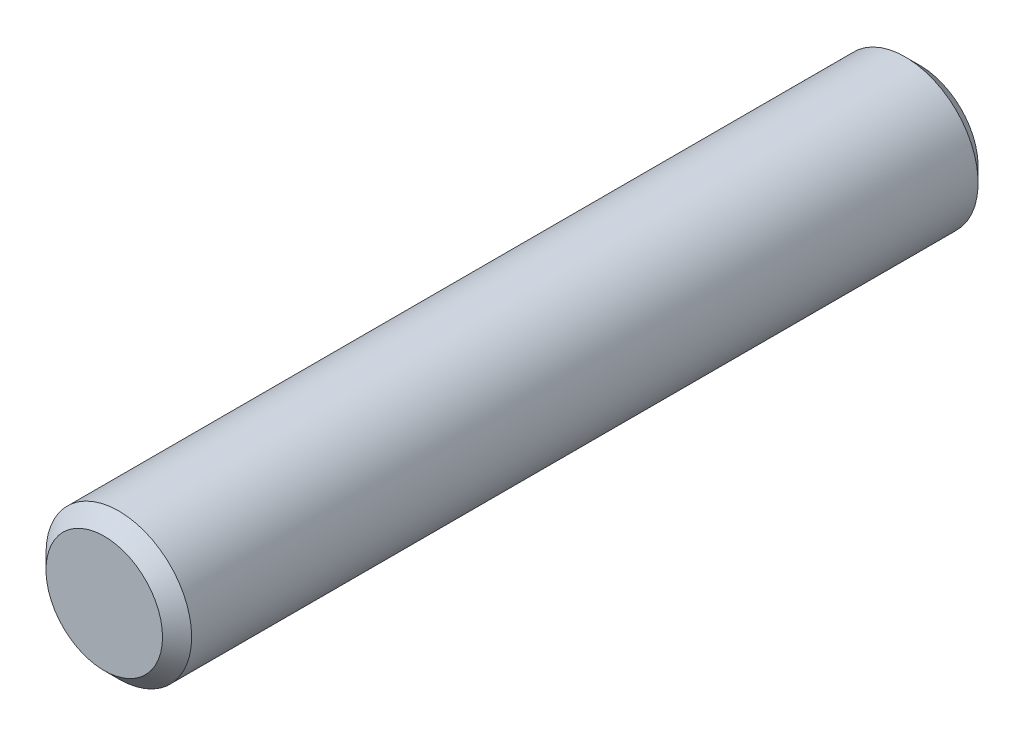
from build123d import *

# Parameters (mm, degrees)
ESBO_O1_W     = 2.5
ESBO_O1_H     = 28
CHANFRO1_SIZE = 0.5


with BuildPart() as part:
    # Esboço1 → Revolução1 (revolve)
    with BuildSketch(Plane.XZ):
        with Locations((1.25, 14)):
            Rectangle(ESBO_O1_W, ESBO_O1_H)
    revolve(axis=Axis((0, 0, 28), (0, 0, -1)))

    # Chanfro1
    chanfro1_edges = [part.edges().sort_by_distance(p)[0] for p in [
        (-2.5, 0, 0),
        (-2.5, 0, 28),
    ]]
    chamfer(chanfro1_edges, length=CHANFRO1_SIZE)


solid = part.part
